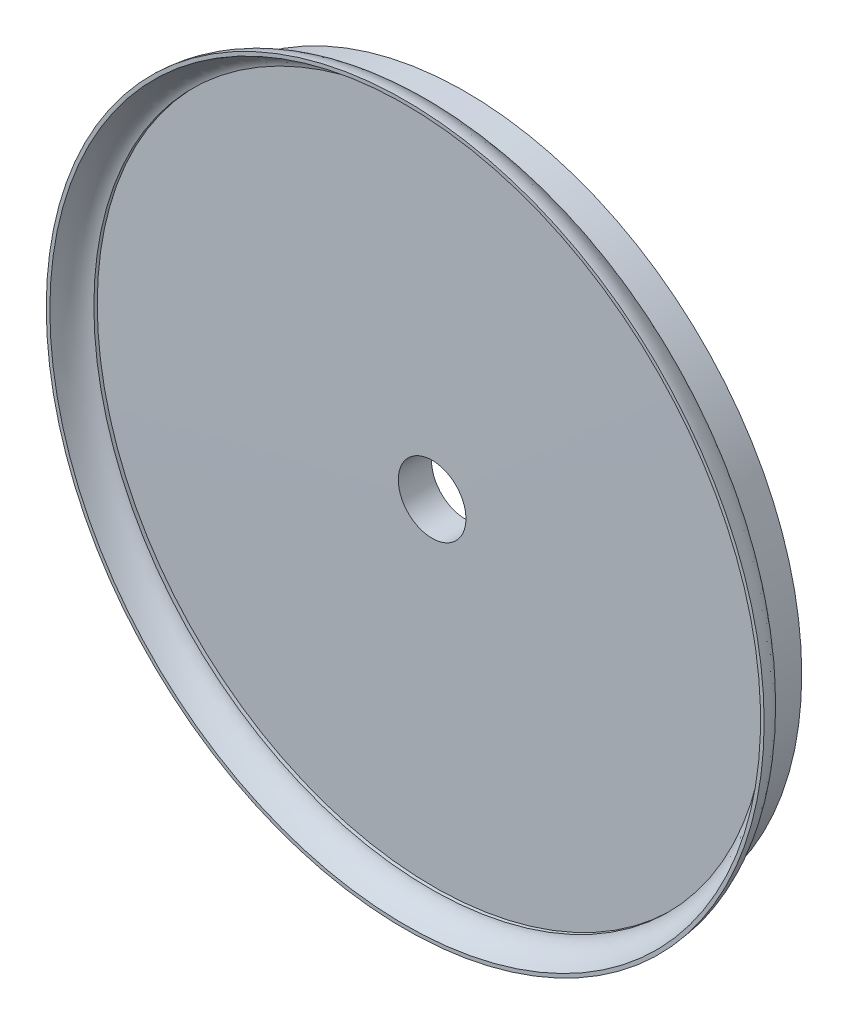
from build123d import *

# Parameters (mm, degrees)
SKETCH1_R           = 44.75
BOSS_EXTRUDE1_DEPTH = 4
SKETCH2_R           = 47.75
BOSS_EXTRUDE2_DEPTH = 4
SKETCH5_R           = 4.5
CUT_EXTRUDE1_DEPTH  = 10


with BuildPart() as part:
    # Sketch1 → Boss-Extrude1 (new body)
    with BuildSketch(Plane.XY):
        Circle(SKETCH1_R)
    extrude(amount=BOSS_EXTRUDE1_DEPTH)

    # Sketch2 → Boss-Extrude2 (add)
    with BuildSketch(Plane.XY.offset(4)):
        Circle(SKETCH2_R)
    extrude(amount=BOSS_EXTRUDE2_DEPTH)

    # Sketch3 → Cut-Revolve1 (revolve, cut)
    with BuildSketch(Plane(origin=(0, 0, 0), x_dir=(0, 0, -1), z_dir=(1, 0, 0))):
        with BuildLine():
            Line((-4, 47.75), (-4, 44.75))
            add(Edge.make_bspline(
                [(-4, 44.75), (-5.51655106, 47.70034682), (-8, 47.75)],
                knots=[0, 0, 0, 0.96689788, 0.96689788, 0.96689788], degree=2))
            Line((-8, 47.75), (-4, 47.75))
        make_face()
    revolve(axis=Axis((0, 0, 14.618090142), (0, 0, -1)), mode=Mode.SUBTRACT)

    # Sketch4 → Cut-Revolve3 (revolve, cut)
    with BuildSketch(Plane(origin=(0, 0, 0), x_dir=(0, 0, -1), z_dir=(1, 0, 0))):
        with BuildLine():
            Line((-4.667863656, 44.75), (-4.217612647, 44.75))
            Line((-4.217612647, 44.75), (-4.442738152, 0))
            Line((-4.442738152, 0), (-8, 0))
            Line((-8, 0), (-8, 47.272851402))
            add(Edge.make_bspline(
                [(-8, 47.272851402), (-5.020669257, 46.35865801), (-4.667863656, 44.75)],
                knots=[0, 0, 0, 0.52721511, 0.52721511, 0.52721511], degree=2))
        make_face()
    revolve(axis=Axis((0, 0, 4.442738152), (0, 0, 1)), mode=Mode.SUBTRACT)

    # Sketch5 → Cut-Extrude1 (cut)
    with BuildSketch(Plane(origin=(0, 0, 0), x_dir=(-1, 0, 0), z_dir=(0, 0, -1))):
        Circle(SKETCH5_R)
    extrude(amount=-CUT_EXTRUDE1_DEPTH, mode=Mode.SUBTRACT)


solid = part.part
